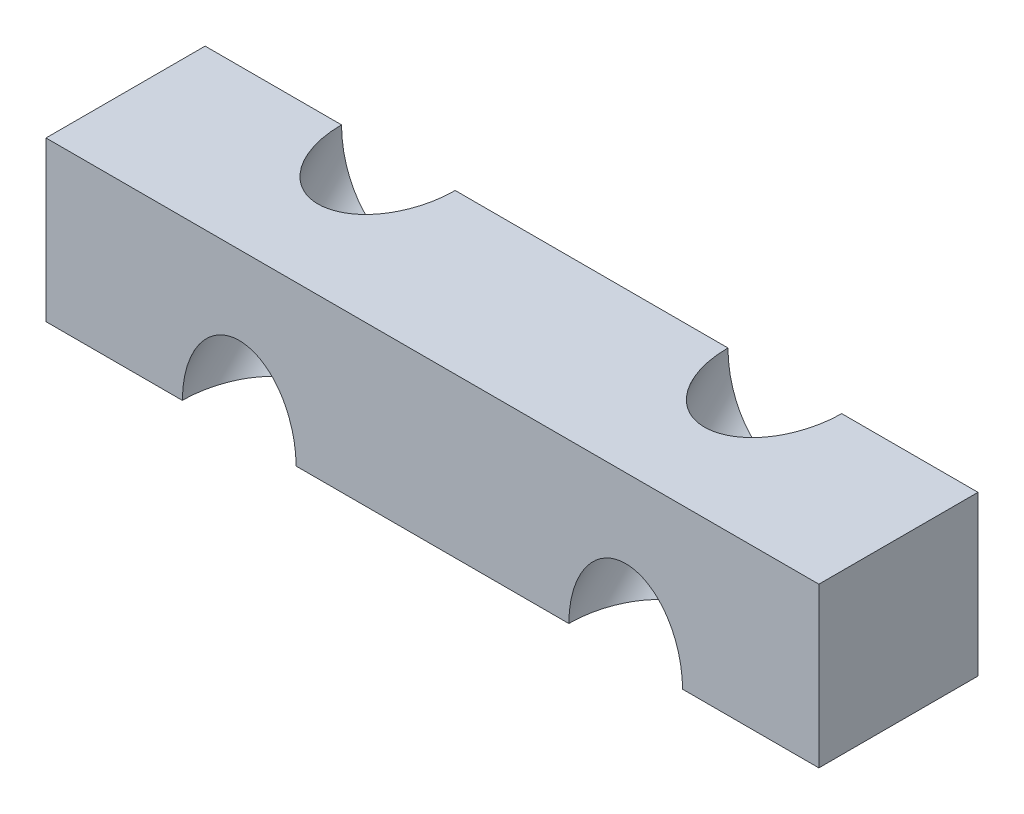
from build123d import *

# Parameters (mm, degrees)
SKETCH1_W               = 34
SKETCH1_H               = 7
BOSS_EXTRUDE1_DEPTH     = 7
SKETCH6_OUTSIDE_W       = 43.082
SKETCH6_OUTSIDE_H       = 18.981
SKETCH6_OUTSIDE_W_2     = 34
SKETCH6_OUTSIDE_H_2     = 9.899494937
SKETCH6_OUTSIDE_R       = 2.5
CUT_EXTRUDE2_DEPTH      = 5.949747468
CUT_EXTRUDE2_DEPTH_BACK = 5.949747468


with BuildPart() as part:
    # sketch1 → Boss-Extrude1 (new body)
    with BuildSketch(Plane(origin=(0, 0, 0), x_dir=(1, 0, 0), z_dir=(0, 1, 0))):
        with Locations((17, -3.5)):
            Rectangle(SKETCH1_W, SKETCH1_H)
    extrude(amount=BOSS_EXTRUDE1_DEPTH)

    # Sketch6 outside → Cut-Extrude2 (cut, two sides)
    with BuildSketch(Plane(origin=(0, 0, 0), x_dir=(-1, 0, 0), z_dir=(0, 0.707106781, -0.707106781))) as cut_extrude2_sk:
        with Locations((-17, 4.9495)):
            Rectangle(SKETCH6_OUTSIDE_W, SKETCH6_OUTSIDE_H)
        with Locations((-17, 4.949747469)):
            Rectangle(SKETCH6_OUTSIDE_W_2, SKETCH6_OUTSIDE_H_2, mode=Mode.SUBTRACT)
        with Locations((-25.5, 4.949747468)):
            Circle(SKETCH6_OUTSIDE_R)
        with Locations((-8.5, 4.949747468)):
            Circle(SKETCH6_OUTSIDE_R)
    extrude(amount=CUT_EXTRUDE2_DEPTH, mode=Mode.SUBTRACT)
    extrude(cut_extrude2_sk.sketch, amount=-CUT_EXTRUDE2_DEPTH_BACK, mode=Mode.SUBTRACT)


solid = part.part
